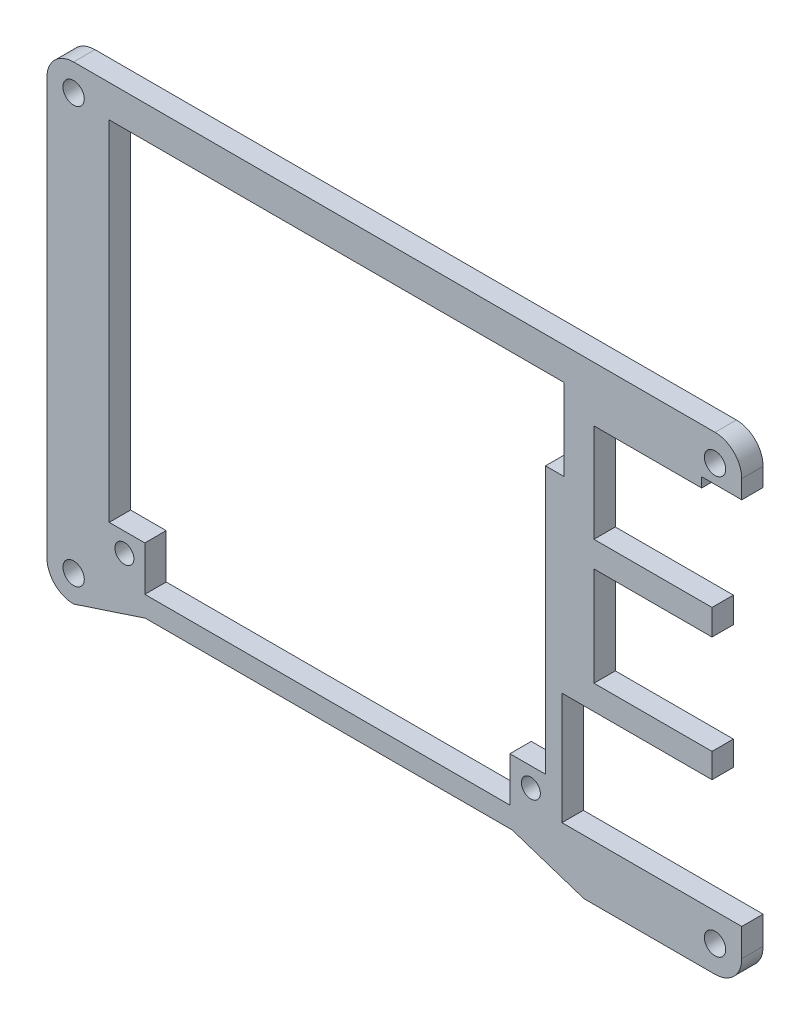
from build123d import *

# Parameters (mm, degrees)
SKETCH1_R           = 1.524
SKETCH1_W           = 60.6932
SKETCH1_H           = 7.81
SKETCH1_W_2         = 5.588
SKETCH1_H_2         = 23.368
SKETCH1_W_3         = 5.4034
SKETCH1_H_3         = 22.6066
BOSS_EXTRUDE1_DEPTH = 3.048
SKETCH2_R           = 10.922
SKETCH2_R_2         = 1.4986
CUT_EXTRUDE1_DEPTH  = 4.048
SKETCH3_W           = 60.6932
SKETCH3_H           = 56.8638
BOSS_EXTRUDE2_DEPTH = 3.048
SKETCH5_W           = 64.8849
SKETCH5_H           = 11.62
SKETCH5_R           = 2.7305
CUT_EXTRUDE3_DEPTH  = 4.048
SKETCH6_R           = 2.7305
SKETCH6_R_2         = 1.35255
BOSS_EXTRUDE3_DEPTH = 3.048
SKETCH7_W           = 15.3651
SKETCH7_H           = 1.397
BOSS_EXTRUDE4_DEPTH = 3.048
SKETCH8_W           = 52.07
SKETCH8_H           = 6.35
CUT_EXTRUDE4_DEPTH  = 4.048


with BuildPart() as part:
    # Sketch1 → Boss-Extrude1 (new body)
    with BuildSketch(Plane.XY):
        with BuildLine():
            Line((61.214907375, 24.068294304), (40.134807375, 24.068294304))
            Line((40.134807375, 24.068294304), (40.134807375, 8.658194304))
            Line((40.134807375, 8.658194304), (56.975007375, 8.658194304))
            Line((56.975007375, 8.658194304), (56.975007375, 4.997894304))
            Line((56.975007375, 4.997894304), (40.134807375, 4.997894304))
            Line((40.134807375, 4.997894304), (40.134807375, -9.121805696))
            Line((40.134807375, -9.121805696), (56.975007375, -9.121805696))
            Line((56.975007375, -9.121805696), (56.975007375, -12.628005696))
            Line((56.975007375, -12.628005696), (35.575007375, -12.628005696))
            Line((35.575007375, -12.628005696), (35.575007375, -28.627805696))
            Line((35.575007375, -28.627805696), (61.214907375, -28.627805696))
            Line((61.214907375, -28.627805696), (61.214907375, -32.613401529))
            ThreePointArc((61.214907375, -32.613401529), (60.108826144, -35.325305244), (57.405007375, -36.451005696))
            Line((57.405007375, -36.451005696), (38.714307375, -36.451005696))
            Line((38.714307375, -36.451005696), (28.474307375, -33.084405696))
            Line((28.474307375, -33.084405696), (-23.844892625, -33.084405696))
            Line((-23.844892625, -33.084405696), (-34.084892625, -36.451005696))
            ThreePointArc((-34.084892625, -36.451005696), (-36.778969461, -35.335082532), (-37.894892625, -32.641005696))
            Line((-37.894892625, -32.641005696), (-37.894892625, 26.697694304))
            ThreePointArc((-37.894892625, 26.697694304), (-36.778969461, 29.391771141), (-34.084892625, 30.507694304))
            Line((-34.084892625, 30.507694304), (57.404932375, 30.507694304))
            ThreePointArc((57.404932375, 30.507694304), (60.103884597, 29.386886916), (61.214907375, 26.683892153))
            Line((61.214907375, 26.683892153), (61.214907375, 24.068294304))
        make_face()
        with Locations((57.405007375, -32.641005696)):
            Circle(SKETCH1_R, mode=Mode.SUBTRACT)
        with Locations((-34.084892625, -32.641005696)):
            Circle(SKETCH1_R, mode=Mode.SUBTRACT)
        with Locations((-34.084892625, 26.697694304)):
            Circle(SKETCH1_R, mode=Mode.SUBTRACT)
        with Locations((57.404932375, 26.697694304)):
            Circle(SKETCH1_R, mode=Mode.SUBTRACT)
        with Locations((1.341707375, 21.991994304)):
            Rectangle(SKETCH1_W, SKETCH1_H, mode=Mode.SUBTRACT)
        with Locations((-26.210892625, -1.882805696)):
            Rectangle(SKETCH1_W_2, SKETCH1_H_2, mode=Mode.SUBTRACT)
        with Locations((16.546707375, -19.663505696)):
            Rectangle(SKETCH1_W_3, SKETCH1_H_3, mode=Mode.SUBTRACT)
    extrude(amount=BOSS_EXTRUDE1_DEPTH)

    # Sketch2 → Cut-Extrude1 (cut, through all)
    with BuildSketch(Plane.XY.offset(3.048)):
        with Locations((-0.302892625, -0.480305696)):
            Circle(SKETCH2_R)
        with Locations((-10.285092625, -10.462505696)):
            Circle(SKETCH2_R_2)
        with Locations((-10.285092625, 9.501894304)):
            Circle(SKETCH2_R_2)
        with Locations((9.679307375, -10.462505696)):
            Circle(SKETCH2_R_2)
        with Locations((9.679307375, 9.501894304)):
            Circle(SKETCH2_R_2)
    extrude(amount=-CUT_EXTRUDE1_DEPTH, mode=Mode.SUBTRACT)

    # Sketch3 → Boss-Extrude2 (add)
    with BuildSketch(Plane.XY.offset(3.048)):
        with Locations((1.341707375, -2.534905696)):
            Rectangle(SKETCH3_W, SKETCH3_H)
    extrude(amount=-BOSS_EXTRUDE2_DEPTH)

    # Sketch5 → Cut-Extrude3 (cut, through all)
    with BuildSketch(Plane.XY.offset(3.048)):
        with Locations((3.437557375, 20.086994304)):
            Rectangle(SKETCH5_W, SKETCH5_H)
        with Locations((-26.839542625, -26.572455696)):
            Circle(SKETCH5_R)
        with Locations((31.135957375, -26.572455696)):
            Circle(SKETCH5_R)
    extrude(amount=-CUT_EXTRUDE3_DEPTH, mode=Mode.SUBTRACT)

    # Sketch6 → Boss-Extrude3 (add)
    with BuildSketch(Plane.XY.offset(3.048)):
        with Locations((-26.839542625, -26.572455696)):
            Circle(SKETCH6_R)
        with Locations((-26.839542625, -26.572455696)):
            Circle(SKETCH6_R_2, mode=Mode.SUBTRACT)
        with Locations((31.135957375, -26.572455696)):
            Circle(SKETCH6_R)
        with Locations((31.135957375, -26.572455696)):
            Circle(SKETCH6_R_2, mode=Mode.SUBTRACT)
    extrude(amount=-BOSS_EXTRUDE3_DEPTH)

    # Sketch7 → Boss-Extrude4 (add)
    with BuildSketch(Plane.XY.offset(3.048)):
        with Locations((47.817357375, 23.369794304)):
            Rectangle(SKETCH7_W, SKETCH7_H)
    extrude(amount=-BOSS_EXTRUDE4_DEPTH)

    # Sketch8 → Cut-Extrude4 (cut, through all)
    with BuildSketch(Plane.XY.offset(3.048)):
        Polygon((-29.004892625, -23.823005696), (-23.924892625, -23.823005696), (28.145107375, -23.823005696), (33.225107375, -23.823005696), (33.225107375, 14.276994304), (-29.004892625, 14.276994304), align=None)
        with Locations((2.110107375, -26.998005696)):
            Rectangle(SKETCH8_W, SKETCH8_H)
    extrude(amount=-CUT_EXTRUDE4_DEPTH, mode=Mode.SUBTRACT)


solid = part.part
